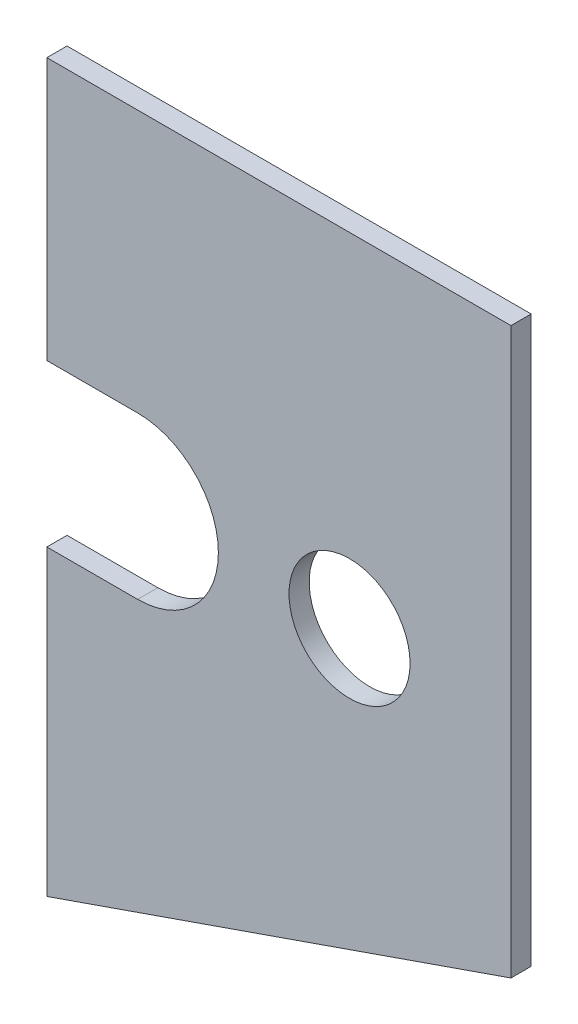
from build123d import *

# Parameters (mm, degrees)
BOSS_EXTRUDE1_DEPTH = 6.35
SKETCH2_R           = 19.05
CUT_EXTRUDE1_DEPTH  = 7.35


with BuildPart() as part:
    # Sketch1 → Boss-Extrude1 (new body)
    with BuildSketch(Plane.XY):
        Polygon((0, 0), (0, 228.6), (146.05, 228.6), (146.05, 50.8), align=None)
    extrude(amount=BOSS_EXTRUDE1_DEPTH)

    # Sketch2 → Cut-Extrude1 (cut, through all)
    with BuildSketch(Plane.XY.offset(6.35)):
        with Locations((95.25, 120.65)):
            Circle(SKETCH2_R)
        with BuildLine():
            Line((0, 146.05), (28.575, 146.05))
            ThreePointArc((28.575, 146.05), (53.975, 120.65), (28.575, 95.25))
            Line((28.575, 95.25), (0, 95.25))
            ThreePointArc((0, 95.25), (-25.4, 120.65), (0, 146.05))
        make_face()
    extrude(amount=-CUT_EXTRUDE1_DEPTH, mode=Mode.SUBTRACT)


solid = part.part
